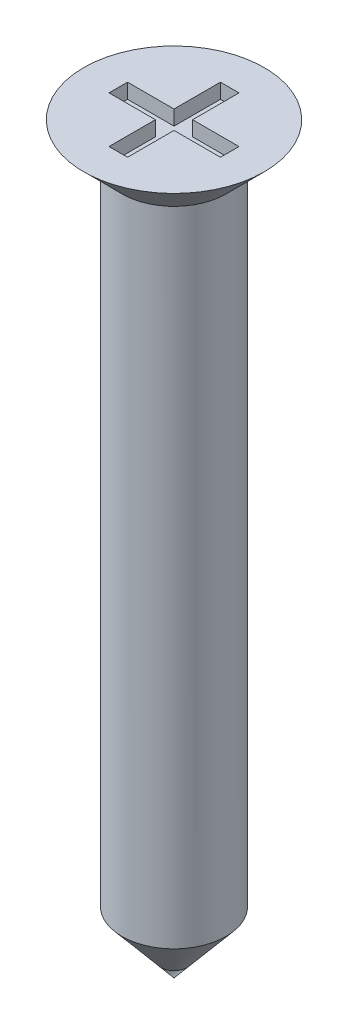
from build123d import *

# Parameters (mm, degrees)
CUT_EXTRUDE1_DEPTH = 0.2


with BuildPart() as part:
    # Sketch1 → Revolve1 (revolve)
    with BuildSketch(Plane.XY):
        Polygon((0, 0), (-1.215, 0), (-0.7, -0.515), (-0.7, -9.165772485), (0, -10), align=None)
    revolve(axis=Axis((0, -10, 0), (0, 1, 0)))

    # Sketch2 → Cut-Extrude1 (cut)
    with BuildSketch(Plane(origin=(0, 0, 0), x_dir=(1, 0, 0), z_dir=(0, 1, 0))):
        Polygon((-0.75, -0.125), (-0.125, -0.125), (-0.125, -0.75), (0.125, -0.75), (0.125, -0.125), (0.75, -0.125), (0.75, 0.125), (0.125, 0.125), (0.125, 0.75), (-0.125, 0.75), (-0.125, 0.125), (-0.75, 0.125), align=None)
    extrude(amount=-CUT_EXTRUDE1_DEPTH, mode=Mode.SUBTRACT)


solid = part.part
